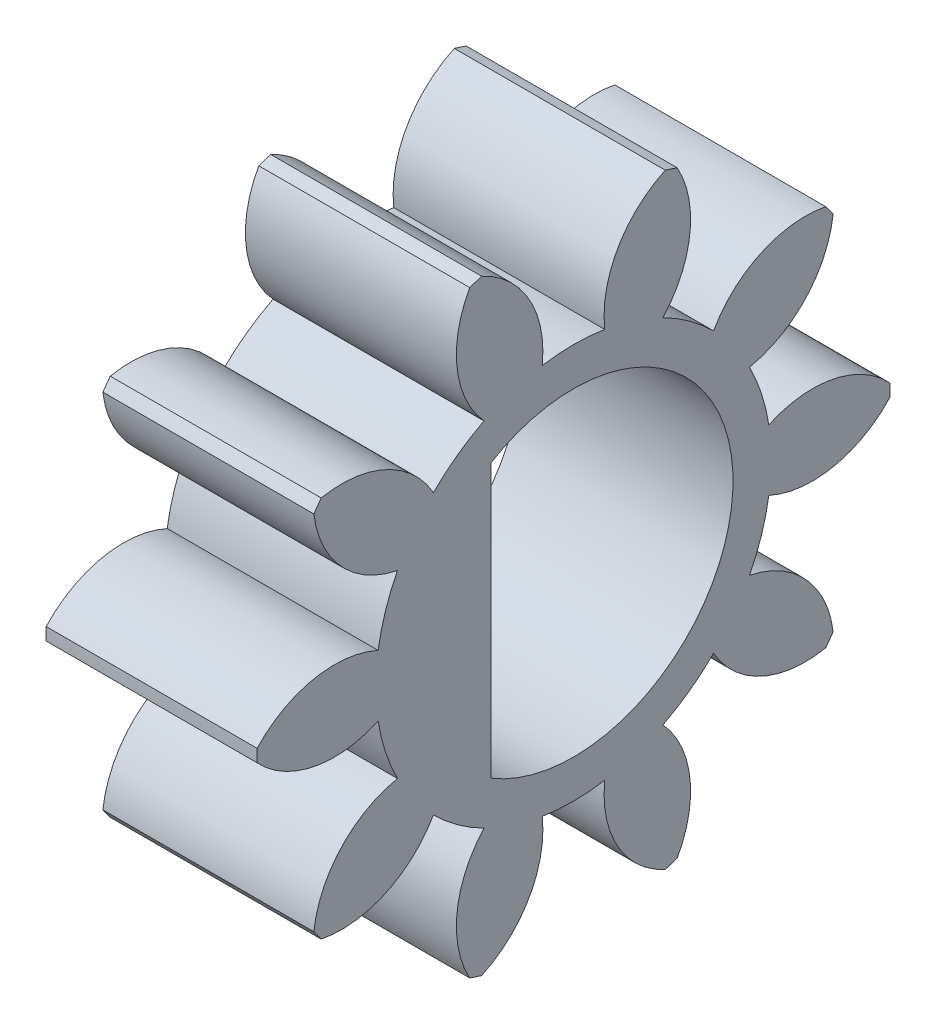
from build123d import *

# Parameters (mm, degrees)
BASPROSKE_W         = 4
BASPROSKE_H         = 6
TOOTHCUT_DEPTH      = 10.38083152
TEETHCUTS_COUNT     = 10
TEETHCUTS_ANGLE     = 324
BORSKE_R            = 3.025
BORE_DEPTH          = 50.0000508
BOSS_EXTRUDE1_DEPTH = 4


with BuildPart() as part:
    # BasProSke → Base-Revolve (revolve)
    with BuildSketch(Plane(origin=(0, 0, 0), x_dir=(1, 0, 0), z_dir=(0, 1, 0)), mode=Mode.PRIVATE) as base_revolve_sk:
        with Locations((2, 3)):
            Rectangle(BASPROSKE_W, BASPROSKE_H)
    revolve(base_revolve_sk.sketch.rotate(Axis((-10, 0, 0), (1, 0, 0)), 180), axis=Axis((-10, 0, 0), (1, 0, 0)))

    # TooCutSke → ToothCut (cut, through all)
    with BuildSketch(Plane(origin=(0, 0, 0), x_dir=(0, 0, -1), z_dir=(1, 0, 0))):
        with BuildLine():
            ThreePointArc((0.59278292, 3.701838653), (0, 3.749), (-0.59278292, 3.701838653))
            ThreePointArc((-0.59278292, 3.701838653), (-0.846593509, 4.924114224), (-1.775771316, 5.757784417))
            ThreePointArc((-1.775771316, 5.757784417), (0, 6.0254), (1.775771316, 5.757784417))
            ThreePointArc((1.775771316, 5.757784417), (0.846593509, 4.924114224), (0.59278292, 3.701838653))
        make_face()
    toothcut = extrude(amount=TOOTHCUT_DEPTH, mode=Mode.SUBTRACT)

    # TeethCuts: ToothCut ×10 about axis
    teethcuts_axis = Axis((-10, 0, 0), (1, 0, 0))
    for i in range(1, TEETHCUTS_COUNT):
        add(toothcut.rotate(teethcuts_axis, i * TEETHCUTS_ANGLE / (TEETHCUTS_COUNT - 1)), mode=Mode.SUBTRACT)

    # BorSke → Bore (cut, symmetric)
    with BuildSketch(Plane(origin=(0, 0, 0), x_dir=(0, 0, -1), z_dir=(1, 0, 0))):
        with Locations(Location((0, 0, 0), (0, 0, 180))):
            Circle(BORSKE_R)
    extrude(amount=BORE_DEPTH, both=True, mode=Mode.SUBTRACT)

    # Sketch1 → Boss-Extrude1 (add)
    with BuildSketch(Plane.ZY):
        with BuildLine():
            ThreePointArc((1.565, -2.588706241), (3.025, 0), (1.565, 2.588706241))
            Line((1.565, 2.588706241), (1.565, -2.588706241))
        make_face()
    extrude(amount=-BOSS_EXTRUDE1_DEPTH)


solid = part.part
